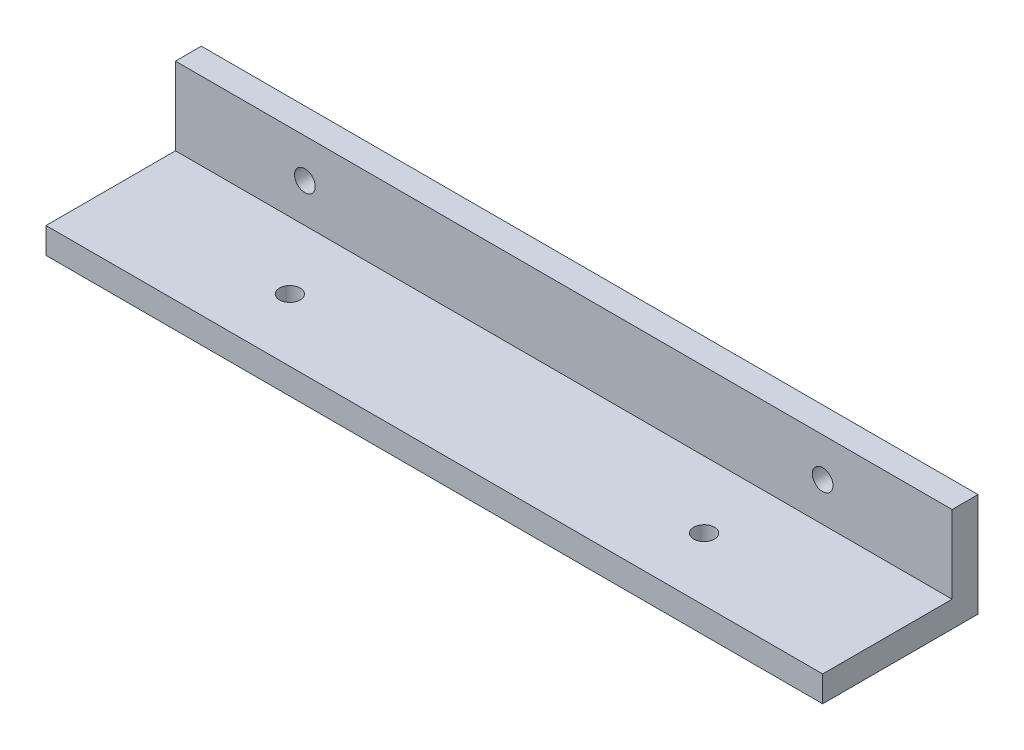
from build123d import *

# Parameters (mm, degrees)
SKETCH1_W           = 150
SKETCH1_H           = 20
BOSS_EXTRUDE1_DEPTH = 5
SKETCH3_W           = 150
SKETCH3_H           = 5
BOSS_EXTRUDE2_DEPTH = 15
SKETCH5_R           = 2
CUT_EXTRUDE1_DEPTH  = 6
SKETCH6_R           = 2
CUT_EXTRUDE2_DEPTH  = 6
SKETCH7_W           = 150
SKETCH7_H           = 5
BOSS_EXTRUDE3_DEPTH = 10


with BuildPart() as part:
    # Sketch1 → Boss-Extrude1 (new body)
    with BuildSketch(Plane(origin=(0, 0, 0), x_dir=(1, 0, 0), z_dir=(0, 1, 0))):
        with Locations((75, 10)):
            Rectangle(SKETCH1_W, SKETCH1_H)
    extrude(amount=-BOSS_EXTRUDE1_DEPTH)

    # Sketch3 → Boss-Extrude2 (add)
    with BuildSketch(Plane(origin=(0, 0, 0), x_dir=(1, 0, 0), z_dir=(0, 1, 0))):
        with Locations((75, 17.5)):
            Rectangle(SKETCH3_W, SKETCH3_H)
    extrude(amount=BOSS_EXTRUDE2_DEPTH)

    # Sketch5 → Cut-Extrude1 (cut, through all)
    with BuildSketch(Plane.XY.offset(-15)):
        with Locations((25, 7.5)):
            Circle(SKETCH5_R)
        with Locations((125, 7.5)):
            Circle(SKETCH5_R)
    extrude(amount=-CUT_EXTRUDE1_DEPTH, mode=Mode.SUBTRACT)

    # Sketch6 → Cut-Extrude2 (cut, through all)
    with BuildSketch(Plane(origin=(0, 0, 0), x_dir=(1, 0, 0), z_dir=(0, 1, 0))):
        with Locations((35, 2.1)):
            Circle(SKETCH6_R)
        with Locations((115, 2.1)):
            Circle(SKETCH6_R)
    extrude(amount=-CUT_EXTRUDE2_DEPTH, mode=Mode.SUBTRACT)

    # Sketch7 → Boss-Extrude3 (add)
    with BuildSketch(Plane.XY):
        with Locations((75, -2.5)):
            Rectangle(SKETCH7_W, SKETCH7_H)
    extrude(amount=BOSS_EXTRUDE3_DEPTH)


solid = part.part
